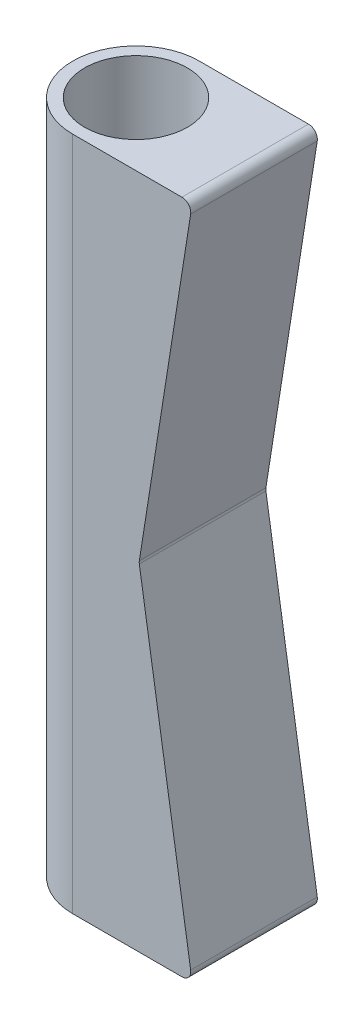
from build123d import *

# Parameters (mm, degrees)
SKETCH1_R           = 14.2875
SKETCH1_R_2         = 11.6125
BOSS_EXTRUDE1_DEPTH = 152.4
SKETCH2_W           = 28.575
SKETCH2_H           = 152.4
BOSS_EXTRUDE2_DEPTH = 12.7
BOSS_EXTRUDE3_DEPTH = 152.4
CUT_EXTRUDE1_DEPTH  = 29.575
FILLET1_R           = 2


with BuildPart() as part:
    # Sketch1 → Boss-Extrude1 (new body)
    with BuildSketch(Plane(origin=(0, 0, 0), x_dir=(1, 0, 0), z_dir=(0, 1, 0))):
        Circle(SKETCH1_R)
        Circle(SKETCH1_R_2, mode=Mode.SUBTRACT)
    extrude(amount=BOSS_EXTRUDE1_DEPTH)



with BuildPart() as body_2:
    # Sketch2 → Boss-Extrude2 (new body)
    with BuildSketch(Plane(origin=(14.2875, 0, 0), x_dir=(0, 0, -1), z_dir=(1, 0, 0))):
        with Locations((0, 76.2)):
            Rectangle(SKETCH2_W, SKETCH2_H)
    extrude(amount=BOSS_EXTRUDE2_DEPTH)


with BuildPart() as part_1:
    add(part.part)

    add(body_2.part)  # Boss-Extrude3 merges body 2
    # Sketch3 → Boss-Extrude3 (add, through all)
    with BuildSketch(Plane(origin=(0, 152.4, 0), x_dir=(1, 0, 0), z_dir=(0, 1, 0))):
        with BuildLine():
            Line((14.2875, -14.2875), (0, -14.2875))
            ThreePointArc((0, -14.2875), (14.2875, 0), (0, 14.2875))
            Line((0, 14.2875), (14.2875, 14.2875))
            Line((14.2875, 14.2875), (26.9875, 14.2875))
            Line((26.9875, 14.2875), (26.9875, -14.2875))
            Line((26.9875, -14.2875), (14.2875, -14.2875))
        make_face()
    extrude(amount=-BOSS_EXTRUDE3_DEPTH)

    # Sketch5 → Cut-Extrude1 (cut, through all)
    with BuildSketch(Plane.XY.offset(14.2875)):
        Polygon((26.9875, 0), (14.9875, 76.2), (26.9875, 152.4), align=None)
    extrude(amount=-CUT_EXTRUDE1_DEPTH, mode=Mode.SUBTRACT)

    # Fillet1
    fillet1_edges = [part_1.edges().sort_by_distance(p)[0] for p in [
        (26.9875, 0, 0),
        (26.9875, 152.4, 0),
        (14.9875, 76.2, 0),
    ]]
    fillet(fillet1_edges, radius=FILLET1_R)


solid = part_1.part
